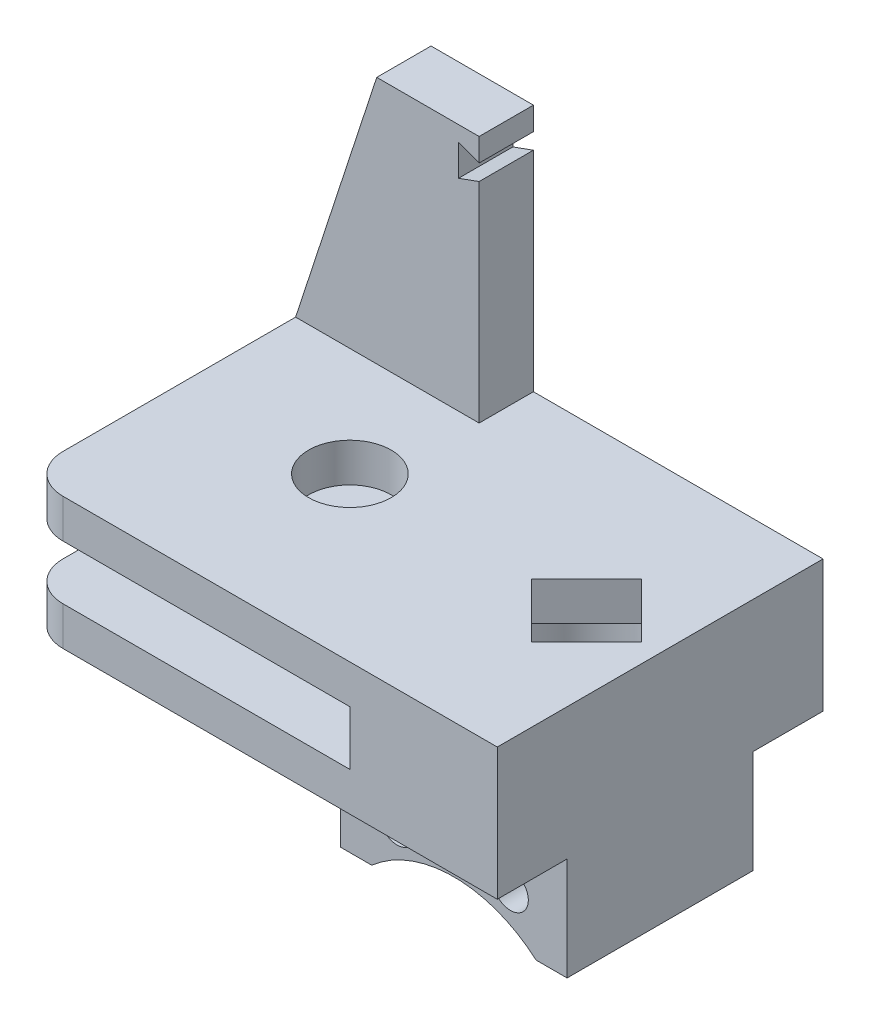
from build123d import *

# Parameters (mm, degrees)
SKETCH1_R            = 3.3782
BOSS_EXTRUDE1_DEPTH  = 3.175
BOSS_EXTRUDE2_DEPTH  = 4.445
SKETCH7_W            = 18.542
SKETCH7_H            = 15.24
BOSS_EXTRUDE4_DEPTH  = 8.43915
SKETCH8_R            = 1.4605
CUT_EXTRUDE3_DEPTH   = 21.955
SKETCH9_R            = 10.16
CUT_EXTRUDE4_DEPTH   = 21.955
CUT_EXTRUDE6_DEPTH   = 9.525
SKETCH23_R           = 4.490128061
CUT_EXTRUDE7_DEPTH   = 6.35
BOSS_EXTRUDE10_DEPTH = 3.175
BOSS_EXTRUDE11_DEPTH = 3.175
SKETCH19_W           = 8.382
SKETCH19_H           = 4.445
BOSS_EXTRUDE12_DEPTH = 20.32
BOSS_EXTRUDE13_DEPTH = 4.445
CUT_EXTRUDE5_DEPTH   = 12.7
FILLET2_R            = 3.175


with BuildPart() as part:
    # Sketch1 → Boss-Extrude1 (new body)
    with BuildSketch(Plane(origin=(0, 0, 0), x_dir=(1, 0, 0), z_dir=(0, 1, 0))):
        with BuildLine():
            Line((0, -13.335), (25.4, -13.335))
            Line((25.4, -13.335), (25.4, 13.335))
            Line((25.4, 13.335), (0, 13.335))
            ThreePointArc((0, 13.335), (-13.335, 0), (0, -13.335))
        make_face()
        Circle(SKETCH1_R, mode=Mode.SUBTRACT)
    boss_extrude1 = extrude(amount=BOSS_EXTRUDE1_DEPTH)

    # Sketch2 → Boss-Extrude2 (add)
    with BuildSketch(Plane(origin=(0, 0, 0), x_dir=(-1, 0, 0), z_dir=(0, -1, 0))):
        Polygon((-25.4, 13.335), (-25.4, -13.335), (-13.335, -13.335), (-13.335, 0), (-13.335, 13.335), align=None)
    extrude(amount=BOSS_EXTRUDE2_DEPTH)

    # Mirror2: Boss-Extrude1 across plane
    add(boss_extrude1.mirror(Plane(origin=(0, -2.2225, 0), x_dir=(0, 0, 1), z_dir=(0, -1, 0))))

    # Sketch7 → Boss-Extrude4 (add)
    with BuildSketch(Plane(origin=(0, -7.62, 0), x_dir=(-1, 0, 0), z_dir=(0, -1, 0))):
        with Locations((-16.129, 0)):
            Rectangle(SKETCH7_W, SKETCH7_H)
    extrude(amount=BOSS_EXTRUDE4_DEPTH)

    # Sketch8 → Cut-Extrude3 (cut, through all)
    with BuildSketch(Plane(origin=(0, 0, -7.62), x_dir=(-1, 0, 0), z_dir=(0, 0, -1))):
        with Locations((-20.7645, -12.1285)):
            Circle(SKETCH8_R)
        with Locations((-11.4935, -12.1285)):
            Circle(SKETCH8_R)
    extrude(amount=-CUT_EXTRUDE3_DEPTH, mode=Mode.SUBTRACT)

    # Sketch9 → Cut-Extrude4 (cut, through all)
    with BuildSketch(Plane(origin=(0, 0, -7.62), x_dir=(-1, 0, 0), z_dir=(0, 0, -1))):
        with Locations((-16.129, -23.67915)):
            Circle(SKETCH9_R)
    extrude(amount=-CUT_EXTRUDE4_DEPTH, mode=Mode.SUBTRACT)

    # Sketch22 → Cut-Extrude6 (cut)
    with BuildSketch(Plane(origin=(0, 3.175, 0), x_dir=(1, 0, 0), z_dir=(0, 1, 0))):
        Polygon((19.3675, -4.490128061), (23.857563833, 0.024016226), (19.3675, 4.490128061), (14.877436167, -0.024016226), align=None)
    extrude(amount=-CUT_EXTRUDE6_DEPTH, mode=Mode.SUBTRACT)

    # Sketch23 → Cut-Extrude7 (cut)
    with BuildSketch(Plane(origin=(0, -6.35, 0), x_dir=(1, 0, 0), z_dir=(0, 1, 0))):
        with Locations((19.3675, 0)):
            Circle(SKETCH23_R)
    extrude(amount=CUT_EXTRUDE7_DEPTH, mode=Mode.SUBTRACT)

    # Sketch16 → Boss-Extrude10 (add)
    with BuildSketch(Plane(origin=(0, 3.175, 0), x_dir=(1, 0, 0), z_dir=(0, 1, 0))):
        Polygon((0, 13.335), (-13.335, 13.335), (-13.335, 0), (-13.335, -13.335), (0, -13.335), (-6.6675, -6.6675), (-6.6675, 6.6675), align=None)
    extrude(amount=-BOSS_EXTRUDE10_DEPTH)

    # Sketch17 → Boss-Extrude11 (add)
    with BuildSketch(Plane.XZ.offset(7.62)):
        Polygon((-13.335, -13.335), (-13.335, 0), (-13.335, 13.335), (0, 13.335), (-6.6675, 6.6675), (-6.6675, -6.6675), (0, -13.335), align=None)
    extrude(amount=-BOSS_EXTRUDE11_DEPTH)

    # Sketch19 → Boss-Extrude12 (add)
    with BuildSketch(Plane(origin=(0, 3.175, 0), x_dir=(1, 0, 0), z_dir=(0, 1, 0))):
        with Locations((-2.5019, 11.1125)):
            Rectangle(SKETCH19_W, SKETCH19_H)
    extrude(amount=BOSS_EXTRUDE12_DEPTH)

    # Sketch20 → Boss-Extrude13 (add)
    with BuildSketch(Plane.XY.offset(-8.89)):
        Polygon((-6.6929, 23.495), (-13.335, 3.175), (-6.6929, 3.175), align=None)
    extrude(amount=-BOSS_EXTRUDE13_DEPTH)

    # Sketch21 → Cut-Extrude5 (cut)
    with BuildSketch(Plane.XY.offset(-8.89)):
        Polygon((0, 22.225), (1.6891, 21.610217877), (1.6891, 20.299782123), (0, 19.685), align=None)
    extrude(amount=-CUT_EXTRUDE5_DEPTH, mode=Mode.SUBTRACT)

    # Fillet2
    fillet2_edges = [part.edges().sort_by_distance(p)[0] for p in [
        (-13.335, 1.5875, 13.335),
        (-13.335, -6.0325, 13.335),
    ]]
    fillet(fillet2_edges, radius=FILLET2_R)


solid = part.part
